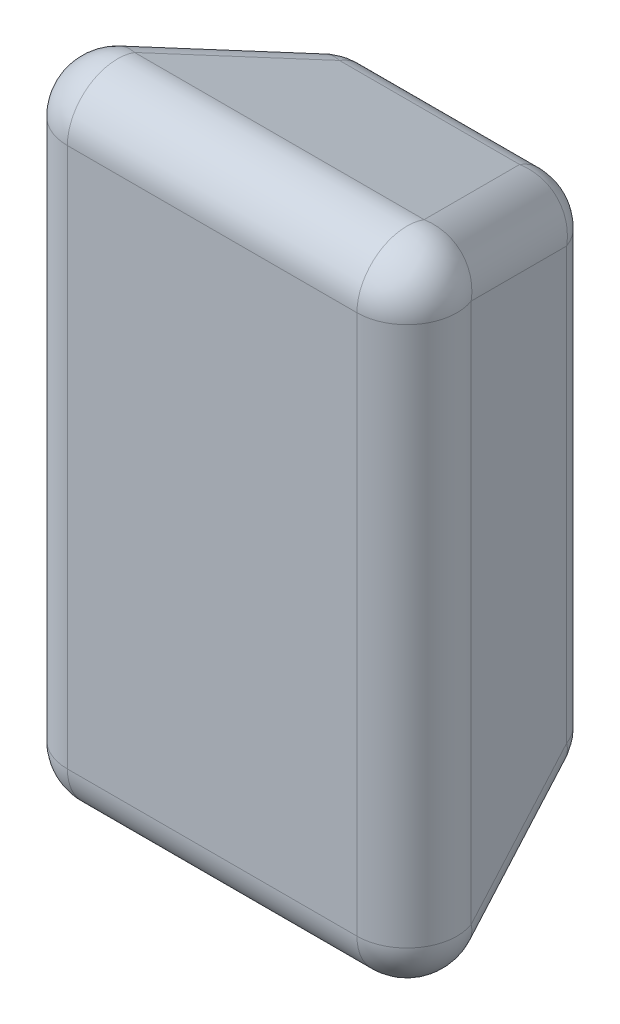
from build123d import *

# Parameters (mm, degrees)
ESQUISSE1_W        = 50
ESQUISSE1_H        = 100
BOSS_EXTRU_1_DEPTH = 50
BOSS_EXTRU_1_DRAFT = -20
CONG_1_R           = 10


with BuildPart() as part:
    # Esquisse1 → Boss.-Extru.1 (with draft: the straight prism first)
    with BuildSketch(Plane.XY):
        with Locations((-3.29344948, -104.237197366)):
            Rectangle(ESQUISSE1_W, ESQUISSE1_H)
    extrude(amount=BOSS_EXTRU_1_DEPTH)
    # Boss.-Extru.1: the draft: its side faces are tilted about the plane it starts from
    boss_extru_1_sides = [part.faces().sort_by_distance(p)[0] for p in [
        (-28.29344948, -104.237197366, 25),
        (-3.29344948, -154.237197366, 25),
        (21.70655052, -104.237197366, 25),
        (-3.29344948, -54.237197366, 25),
    ]]
    draft(boss_extru_1_sides, Plane.XY, BOSS_EXTRU_1_DRAFT)

    # Congé1
    cong_1_edges = [part.edges().sort_by_distance(p)[0] for p in [
        (39.905062233, -104.237197366, 50),
        (-3.29344948, -36.038685653, 50),
        (-46.491961194, -104.237197366, 50),
        (-3.29344948, -54.237197366, 0),
        (21.70655052, -104.237197366, 0),
        (-3.29344948, -154.237197366, 0),
        (-28.29344948, -104.237197366, 0),
        (-37.392705337, -45.137941509, 25),
        (30.805806376, -45.137941509, 25),
        (30.805806376, -163.336453223, 25),
        (-37.392705337, -163.336453223, 25),
        (-3.29344948, -172.435709079, 50),
    ]]
    fillet(cong_1_edges, radius=CONG_1_R)


solid = part.part
